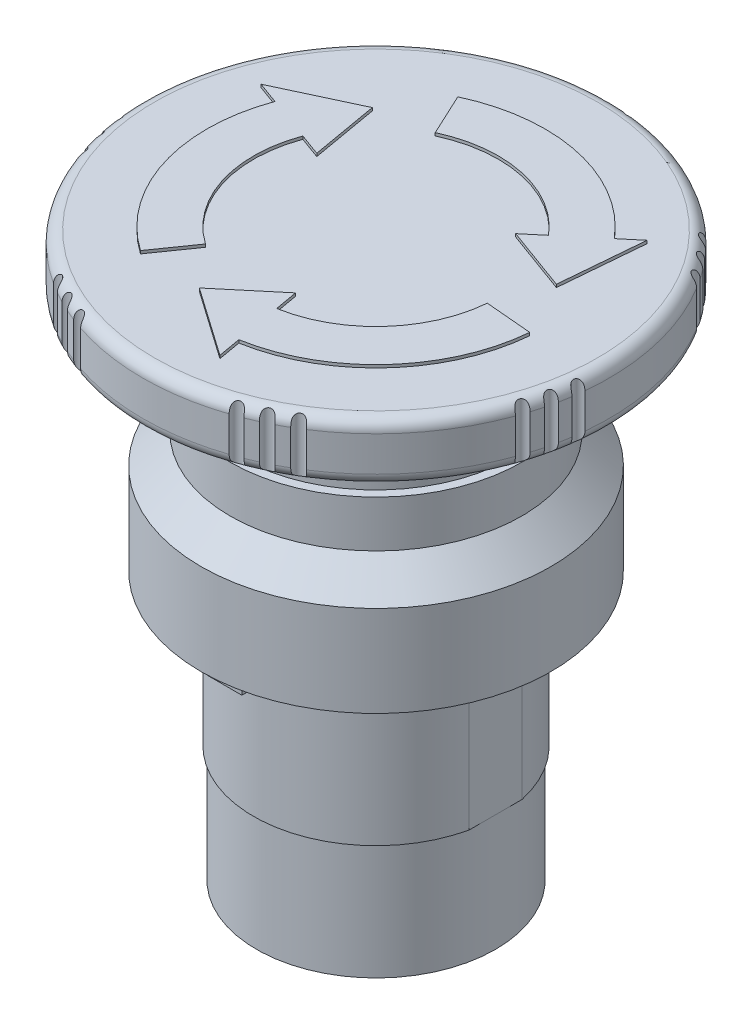
from build123d import *

# Parameters (mm, degrees)
SKETCH1_R            = 15
BOSS_EXTRUDE1_DEPTH  = 6.3
SKETCH2_R            = 15
BOSS_EXTRUDE2_DEPTH  = 1.5
SKETCH3_R            = 15
BOSS_EXTRUDE3_DEPTH  = 2.5
BOSS_EXTRUDE3_TAPER  = 45
SKETCH4_R            = 12.5
BOSS_EXTRUDE4_DEPTH  = 4
SKETCH5_R            = 11.75
CUT_EXTRUDE1_DEPTH   = 14
SKETCH6_R            = 11.25
BOSS_EXTRUDE5_DEPTH  = 20
SKETCH8_R            = 20
BOSS_EXTRUDE7_DEPTH  = 5
FILLET1_R            = 1
SKETCH9_R            = 0.5
CUT_EXTRUDE2_DEPTH   = 15
BOSS_EXTRUDE8_DEPTH  = 0.25
BOSS_EXTRUDE9_DEPTH  = 2
SKETCH13_R           = 10.5
BOSS_EXTRUDE10_DEPTH = 11
SKETCH14_R           = 10.25
BOSS_EXTRUDE11_DEPTH = 10
SKETCH15_W           = 10
SKETCH15_H           = 30
CUT_EXTRUDE3_DEPTH   = 21


with BuildPart() as part:
    # Sketch1 → Boss-Extrude1 (new body)
    with BuildSketch(Plane(origin=(0, 0, 0), x_dir=(1, 0, 0), z_dir=(0, 1, 0))):
        Circle(SKETCH1_R)
    extrude(amount=BOSS_EXTRUDE1_DEPTH)

    # Sketch2 → Boss-Extrude2 (add)
    with BuildSketch(Plane(origin=(0, 6.3, 0), x_dir=(1, 0, 0), z_dir=(0, 1, 0))):
        Circle(SKETCH2_R)
    extrude(amount=BOSS_EXTRUDE2_DEPTH)

    # Sketch3 → Boss-Extrude3 (add)
    with BuildSketch(Plane(origin=(0, 7.8, 0), x_dir=(1, 0, 0), z_dir=(0, 1, 0))):
        Circle(SKETCH3_R)
    extrude(amount=BOSS_EXTRUDE3_DEPTH, taper=BOSS_EXTRUDE3_TAPER)

    # Sketch4 → Boss-Extrude4 (add)
    with BuildSketch(Plane(origin=(0, 10.3, 0), x_dir=(1, 0, 0), z_dir=(0, 1, 0))):
        Circle(SKETCH4_R)
    extrude(amount=BOSS_EXTRUDE4_DEPTH)

    # Sketch5 → Cut-Extrude1 (cut)
    with BuildSketch(Plane(origin=(0, 14.3, 0), x_dir=(1, 0, 0), z_dir=(0, 1, 0))):
        Circle(SKETCH5_R)
    extrude(amount=-CUT_EXTRUDE1_DEPTH, mode=Mode.SUBTRACT)

    # Sketch6 → Boss-Extrude5 (add)
    with BuildSketch(Plane(origin=(0, 0.3, 0), x_dir=(1, 0, 0), z_dir=(0, 1, 0))):
        Circle(SKETCH6_R)
    extrude(amount=BOSS_EXTRUDE5_DEPTH)

    # Sketch8 → Boss-Extrude7 (add)
    with BuildSketch(Plane(origin=(0, 20.3, 0), x_dir=(1, 0, 0), z_dir=(0, 1, 0))):
        Circle(SKETCH8_R)
    extrude(amount=BOSS_EXTRUDE7_DEPTH)

    # Fillet1
    fillet1_edges = [part.edges().sort_by_distance(p)[0] for p in [
        (-20, 20.3, 0),
        (-20, 25.3, 0),
    ]]
    fillet(fillet1_edges, radius=FILLET1_R)

    # Sketch9 → Cut-Extrude2 (cut)
    with BuildSketch(Plane(origin=(0, 25.3, 0), x_dir=(1, 0, 0), z_dir=(0, 1, 0))):
        with Locations((2, 19.947245594)):
            Circle(SKETCH9_R)
        with Locations((0, 20.047259333)):
            Circle(SKETCH9_R)
        with Locations((-2, 19.947245594)):
            Circle(SKETCH9_R)
        with Locations((16.842364197, 10.873241238)):
            Circle(SKETCH9_R)
        with Locations((15.673578484, 12.49926175)):
            Circle(SKETCH9_R)
        with Locations((14.34840499, 14.000567168)):
            Circle(SKETCH9_R)
        with Locations((19.002084633, -6.388535544)):
            Circle(SKETCH9_R)
        with Locations((19.544632687, -4.46093487)):
            Circle(SKETCH9_R)
        with Locations((19.892168368, -2.488823895)):
            Circle(SKETCH9_R)
        with Locations((6.852847768, -18.839614759)):
            Circle(SKETCH9_R)
        with Locations((8.698179839, -18.061956546)):
            Circle(SKETCH9_R)
        with Locations((10.456723239, -17.104079802)):
            Circle(SKETCH9_R)
        with Locations((-10.456723239, -17.104079802)):
            Circle(SKETCH9_R)
        with Locations((-8.698179839, -18.061956546)):
            Circle(SKETCH9_R)
        with Locations((-6.852847768, -18.839614759)):
            Circle(SKETCH9_R)
        with Locations((-19.892168368, -2.488823895)):
            Circle(SKETCH9_R)
        with Locations((-19.544632687, -4.46093487)):
            Circle(SKETCH9_R)
        with Locations((-19.002084633, -6.388535544)):
            Circle(SKETCH9_R)
        with Locations((-14.34840499, 14.000567168)):
            Circle(SKETCH9_R)
        with Locations((-15.673578484, 12.49926175)):
            Circle(SKETCH9_R)
        with Locations((-16.842364197, 10.873241238)):
            Circle(SKETCH9_R)
    extrude(amount=-CUT_EXTRUDE2_DEPTH, mode=Mode.SUBTRACT)

    # Sketch10 → Boss-Extrude8 (add)
    with BuildSketch(Plane(origin=(0, 25.3, 0), x_dir=(1, 0, 0), z_dir=(0, 1, 0))):
        with BuildLine():
            Line((-13.625543001, 4.959292078), (-15.504928243, 5.643332365))
            Line((-15.504928243, 5.643332365), (-8.996575887, 8.67822691))
            Line((-8.996575887, 8.67822691), (-7.987387277, 2.907171218))
            Line((-7.987387277, 2.907171218), (-9.866772518, 3.591211505))
            ThreePointArc((-9.866772518, 3.591211505), (-10.014027983, -3.157410895), (-6.022552582, -8.601096465))
            Line((-6.022552582, -8.601096465), (-8.316858327, -11.877704642))
            ThreePointArc((-8.316858327, -11.877704642), (-13.828895786, -4.360234093), (-13.625543001, 4.959292078))
        make_face()
        with BuildLine():
            Line((6.511377767, 5.463694682), (12.013852908, 3.45214981))
            ThreePointArc((12.013852908, 3.45214981), (5.180501974, 11.375957072), (-5.282728272, 11.328847338))
            Line((-5.282728272, 11.328847338), (-4.437491748, 9.516231764))
            ThreePointArc((-4.437491748, 9.516231764), (2.272615946, 10.251108075), (8.043466653, 6.749269902))
            Line((8.043466653, 6.749269902), (6.511377767, 5.463694682))
        make_face()
        with BuildLine():
            Line((12.639733311, 10.60599556), (11.107644425, 9.32042034))
            ThreePointArc((11.107644425, 9.32042034), (3.138374402, 14.156292103), (-6.127964795, 13.141462912))
            Line((-6.127964795, 13.141462912), (-5.282728272, 11.328847338))
            ThreePointArc((-5.282728272, 11.328847338), (5.180501974, 11.375957072), (12.013852908, 3.45214981))
            Line((12.013852908, 3.45214981), (12.639733311, 10.60599556))
        make_face()
        with BuildLine():
            Line((2.517898576, -14.279712419), (2.865194932, -16.249327925))
            Line((2.865194932, -16.249327925), (-3.017277021, -12.13037672))
            Line((-3.017277021, -12.13037672), (1.47600951, -8.370865901))
            Line((1.47600951, -8.370865901), (1.823305866, -10.340481407))
            ThreePointArc((1.823305866, -10.340481407), (7.741412037, -7.09369718), (10.46004433, -0.915135299))
            Line((10.46004433, -0.915135299), (14.444823122, -1.26375827))
            ThreePointArc((14.444823122, -1.26375827), (10.690521384, -9.79605801), (2.517898576, -14.279712419))
        make_face()
    extrude(amount=BOSS_EXTRUDE8_DEPTH)

    # Sketch12 → Boss-Extrude9 (add)
    with BuildSketch(Plane.XZ):
        with BuildLine():
            Line((1.5, 10.897247359), (1.5, 13))
            Line((1.5, 13), (-1.5, 13))
            Line((-1.5, 13), (-1.5, 10.897247359))
            ThreePointArc((-1.5, 10.897247359), (0, -11), (1.5, 10.897247359))
        make_face()
    extrude(amount=BOSS_EXTRUDE9_DEPTH)

    # Sketch13 → Boss-Extrude10 (add)
    with BuildSketch(Plane.XZ.offset(2)):
        Circle(SKETCH13_R)
    extrude(amount=BOSS_EXTRUDE10_DEPTH)

    # Sketch14 → Boss-Extrude11 (add)
    with BuildSketch(Plane.XZ.offset(13)):
        Circle(SKETCH14_R)
    extrude(amount=BOSS_EXTRUDE11_DEPTH)

    # Sketch15 → Cut-Extrude3 (cut)
    with BuildSketch(Plane.XZ.offset(23)):
        with Locations((-15.25, 0)):
            Rectangle(SKETCH15_W, SKETCH15_H)
        with Locations((15.25, 0.998046756)):
            Rectangle(SKETCH15_W, SKETCH15_H)
    extrude(amount=-CUT_EXTRUDE3_DEPTH, mode=Mode.SUBTRACT)


solid = part.part
